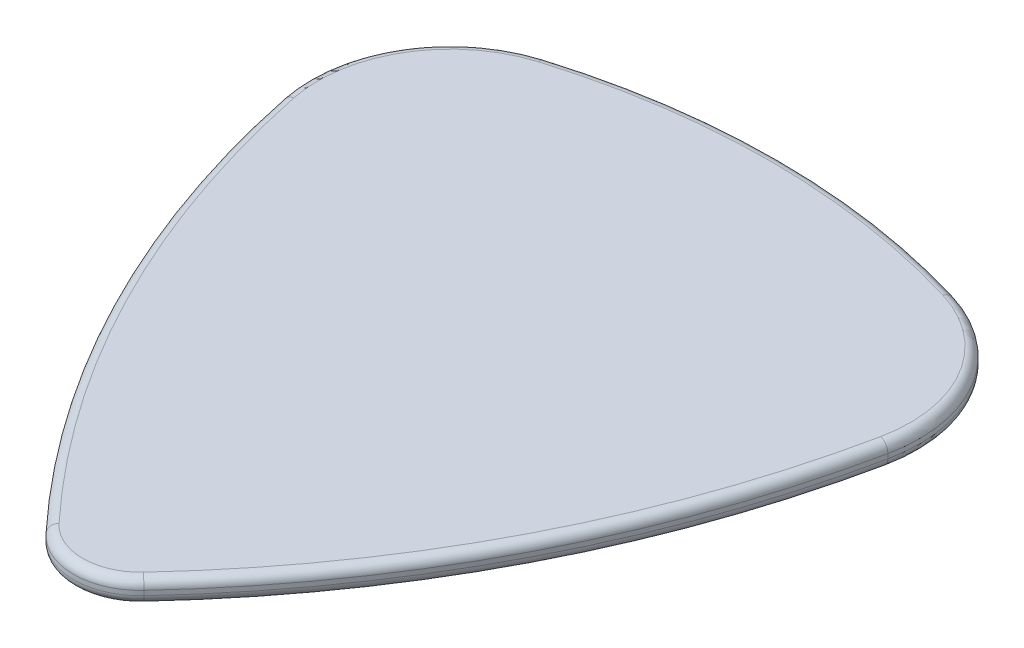
from build123d import *

# Parameters (mm, degrees)
BOSS_EXTRUDE1_DEPTH = 1
FILLET1_R           = 0.4


with BuildPart() as part:
    # Sketch1 → Boss-Extrude1 (new body)
    with BuildSketch(Plane(origin=(0, 0, 0), x_dir=(1, 0, 0), z_dir=(0, 1, 0))):
        with BuildLine():
            ThreePointArc((-8.877423872, 29.304875795), (0, 30.62), (8.877423872, 29.304875795))
            ThreePointArc((8.877423872, 29.304875795), (12.375173273, 26.566048159), (13.11, 22.184786084))
            ThreePointArc((13.11, 22.184786084), (9.076207285, 10.799312083), (2.121856975, 0.92320386))
            ThreePointArc((2.121856975, 0.92320386), (0, 0), (-2.121856975, 0.92320386))
            ThreePointArc((-2.121856975, 0.92320386), (-9.076207285, 10.799312083), (-13.11, 22.184786084))
            ThreePointArc((-13.11, 22.184786084), (-12.375173273, 26.566048159), (-8.877423872, 29.304875795))
        make_face()
    extrude(amount=BOSS_EXTRUDE1_DEPTH)

    # Fillet1
    fillet1_edges = [part.edges().sort_by_distance(p)[0] for p in [
        (0, 1, 0),
        (9.076207285, 1, -10.799312083),
        (12.375173273, 1, -26.566048159),
        (0, 1, -30.62),
        (-12.375173273, 1, -26.566048159),
        (0, 0, -30.62),
        (12.375173273, 0, -26.566048159),
        (9.076207285, 0, -10.799312083),
        (0, 0, 0),
        (-9.076207285, 0, -10.799312083),
        (-12.375173273, 0, -26.566048159),
        (-9.076207285, 1, -10.799312083),
    ]]
    fillet(fillet1_edges, radius=FILLET1_R)


solid = part.part
